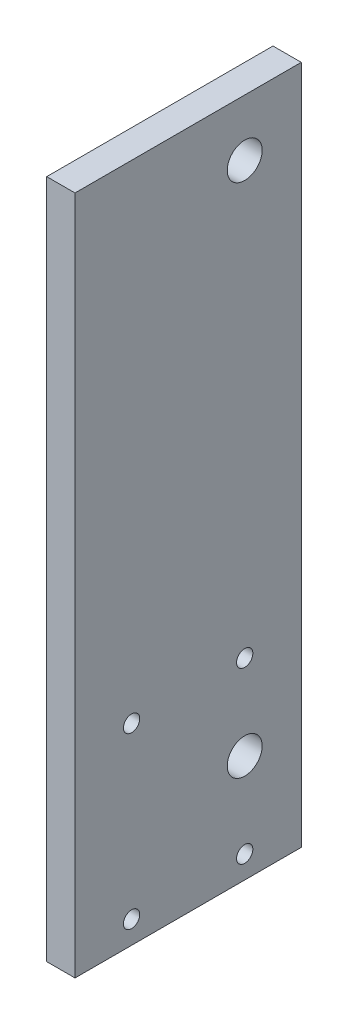
from build123d import *

# Parameters (mm, degrees)
SKETCH1_W             = 50.8
SKETCH1_H             = 152.654
SKETCH1_R             = 3.925
BOSS_EXTRUDE1_DEPTH   = 3.175
F_6_CLEARANCE_HOLE1_D = 3.6576


with BuildPart() as part:
    # Sketch1 → Boss-Extrude1 (new, symmetric)
    with BuildSketch(Plane(origin=(0, 0, 0), x_dir=(0, 0, -1), z_dir=(1, 0, 0))):
        with Locations((-12.7, -63.627)):
            Rectangle(SKETCH1_W, SKETCH1_H)
        Circle(SKETCH1_R, mode=Mode.SUBTRACT)
        with Locations((0, -115.824)):
            Circle(SKETCH1_R, mode=Mode.SUBTRACT)
    extrude(amount=BOSS_EXTRUDE1_DEPTH, both=True)

    # 6 Clearance Hole1 (through all)
    with Locations(Plane.ZY.offset(3.175)):
        with Locations((0, -96.774), (25.4, -96.774), (25.4, -134.874), (0, -134.874)):
            Hole(F_6_CLEARANCE_HOLE1_D / 2)


solid = part.part
